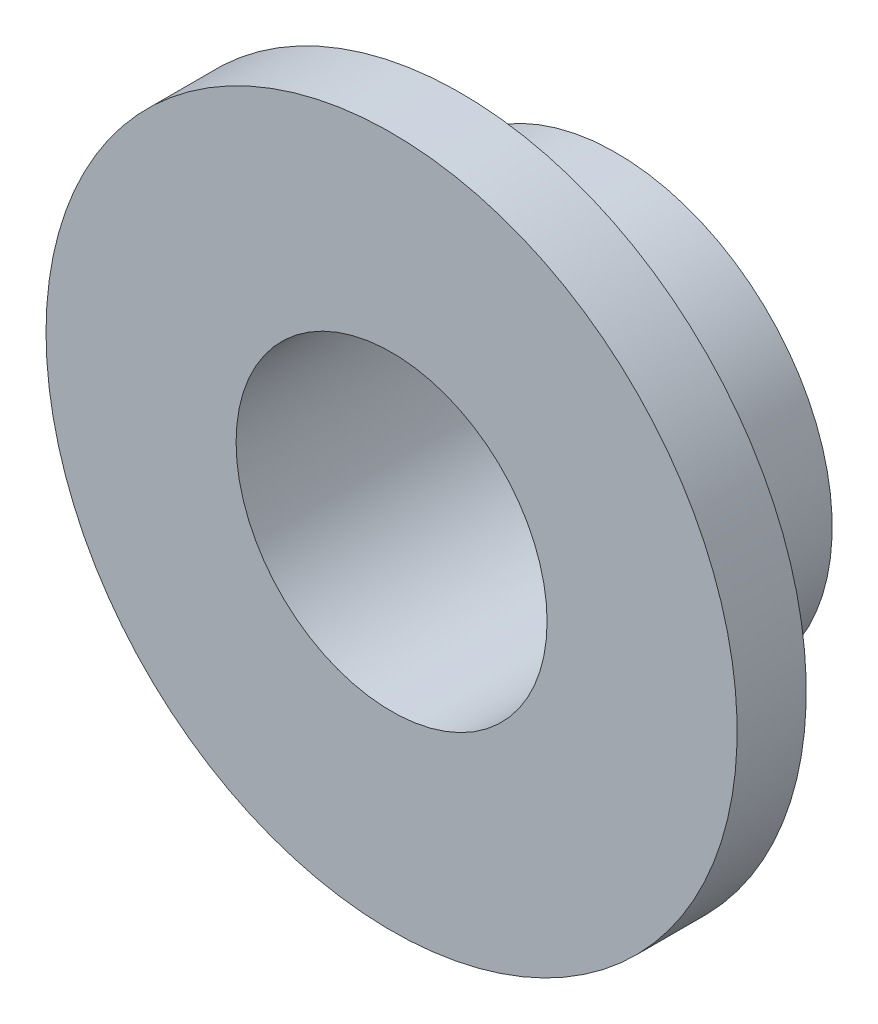
from build123d import *


with BuildPart() as part:
    # Эскиз1 → Повернуть1 (revolve)
    with BuildSketch(Plane(origin=(0, 0, 0), x_dir=(0, 0, -1), z_dir=(1, 0, 0))):
        Polygon((4, 4.5), (4, 6.25), (-0.5, 6.25), (-0.5, 10), (-2.5, 10), (-2.5, 4.5), align=None)
    revolve(axis=Axis((0, 0, -8), (0, 0, 1)))


solid = part.part
